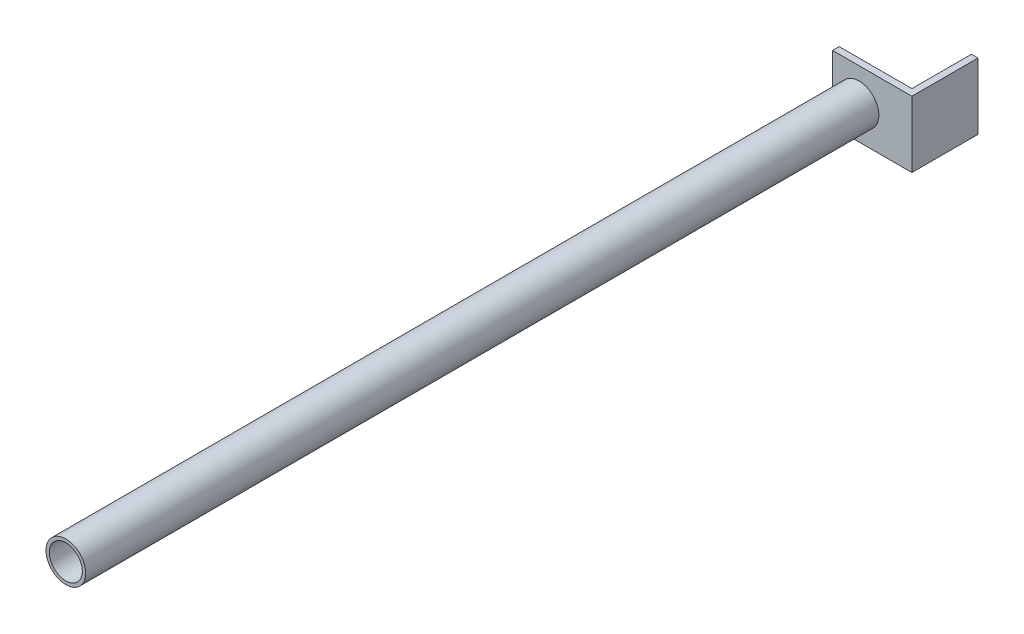
from build123d import *

# Parameters (mm, degrees)
BOSS_EXTRUDE1_DEPTH = 31.75
SKETCH2_R           = 19.05
SKETCH2_R_2         = 15.875
BOSS_EXTRUDE2_DEPTH = 762


with BuildPart() as part:
    # Sketch1 → Boss-Extrude1 (new body, symmetric)
    with BuildSketch(Plane(origin=(0, 0, 0), x_dir=(1, 0, 0), z_dir=(0, 1, 0))):
        Polygon((0, 31.75), (0, -31.75), (-76.2, -31.75), (-76.2, -25.4), (-6.35, -25.4), (-6.35, 31.75), align=None)
    extrude(amount=BOSS_EXTRUDE1_DEPTH, both=True)

    # Sketch2 → Boss-Extrude2 (add)
    with BuildSketch(Plane.XY.offset(31.75)):
        with Locations((-50.8, 0)):
            Circle(SKETCH2_R)
        with Locations((-50.8, 0)):
            Circle(SKETCH2_R_2, mode=Mode.SUBTRACT)
    extrude(amount=BOSS_EXTRUDE2_DEPTH)


solid = part.part
